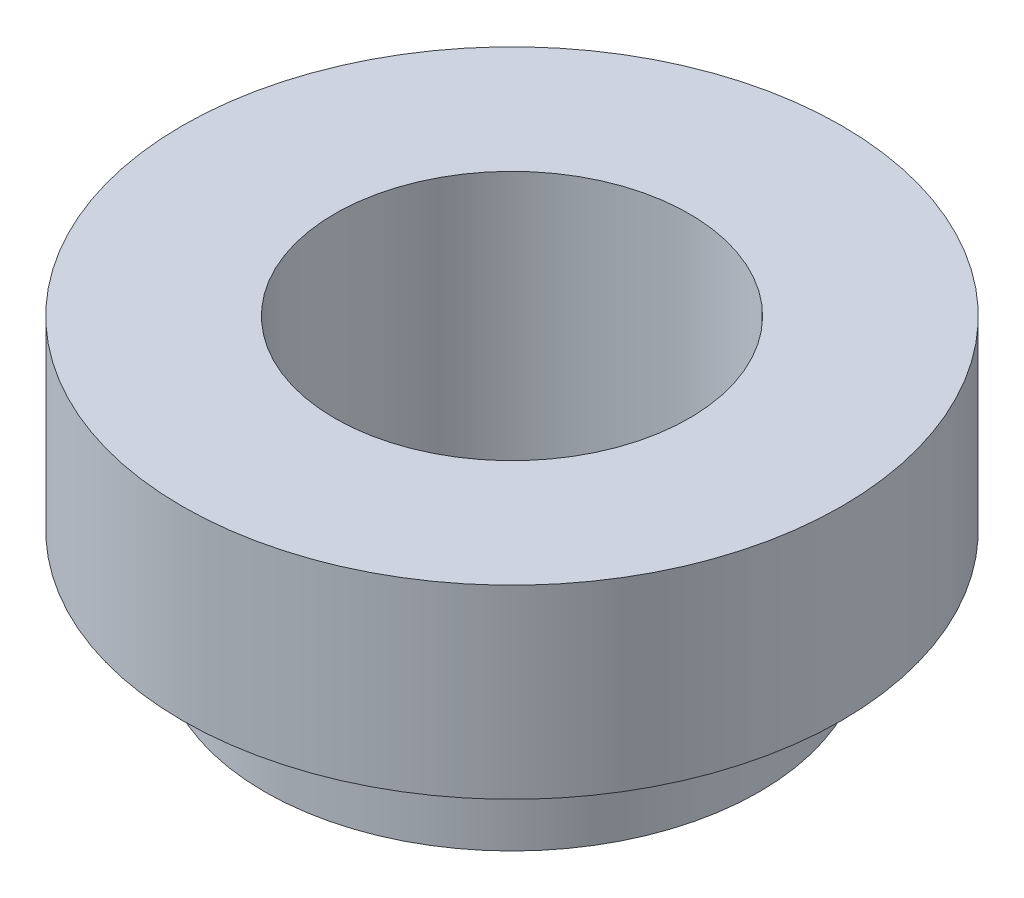
from build123d import *

# Parameters (mm, degrees)
SKETCH3_R          = 4.3
CUT_EXTRUDE1_DEPTH = 8


with BuildPart() as part:
    # Sketch2 → Revolve1 (revolve)
    with BuildSketch(Plane.XY):
        Polygon((0, 0), (-8, 0), (-8, -4.5), (-6, -4.5), (-6, -7), (0, -7), align=None)
    revolve(axis=Axis((0, -55, 0), (0, 1, 0)))

    # Sketch3 → Cut-Extrude1 (cut, through all)
    with BuildSketch(Plane(origin=(0, 0, 0), x_dir=(1, 0, 0), z_dir=(0, 1, 0))):
        Circle(SKETCH3_R)
    extrude(amount=-CUT_EXTRUDE1_DEPTH, mode=Mode.SUBTRACT)


solid = part.part
